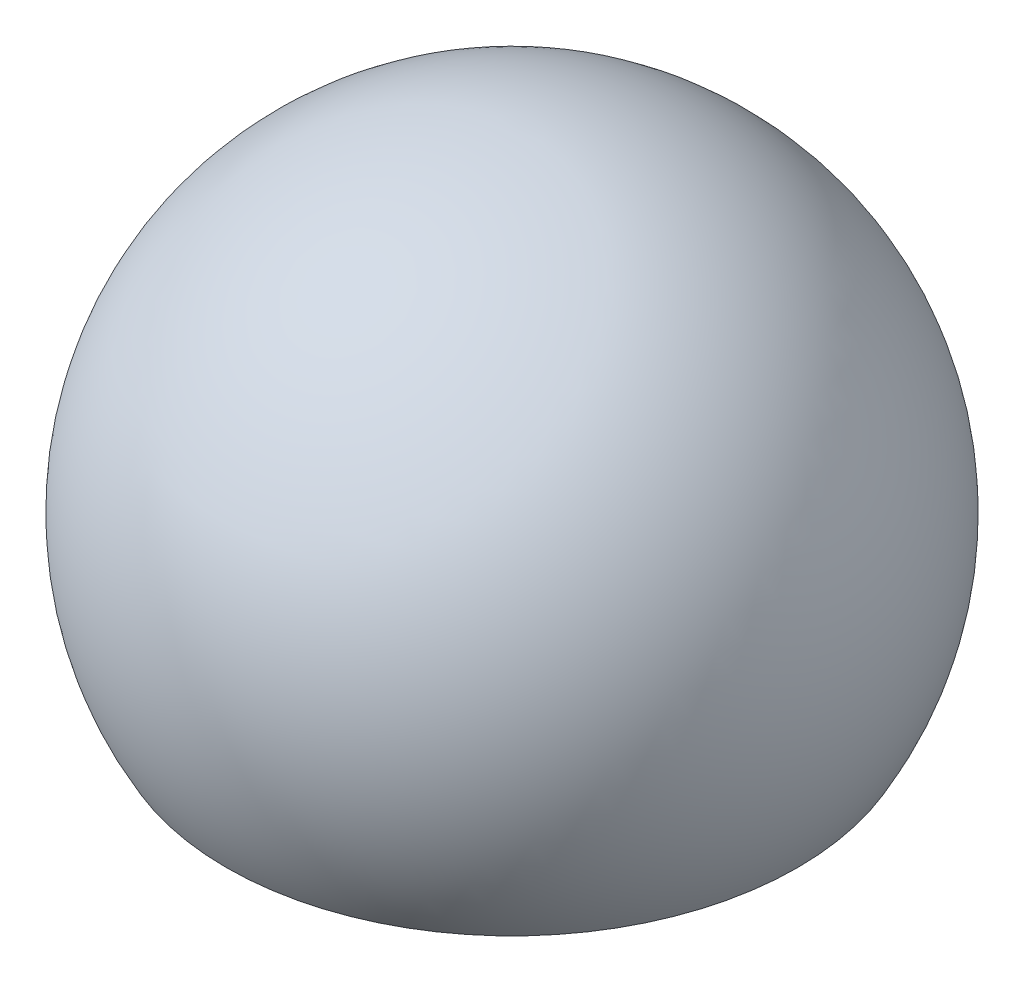
from build123d import *

# Parameters (mm, degrees)
TRUNCATED_BALL_DEPTH      = 13.7
TRUNCATED_BALL_DEPTH_BACK = 13.7
SKETCH8_W                 = 1.5875
SKETCH8_H                 = 11.1125


with BuildPart() as part:
    # Sketch1 → Complete_Ball (revolve)
    with BuildSketch(Plane.XY):
        with BuildLine():
            Line((0, 12.7), (0, -12.7))
            ThreePointArc((0, -12.7), (12.7, 0), (0, 12.7))
        make_face()
    revolve(axis=Axis((0, 13.6525, 0), (0, -1, 0)))

    # Sketch2 → Truncated_ball (cut, two sides)
    with BuildSketch(Plane.XY) as truncated_ball_sk:
        with BuildLine():
            Line((-10.998522628, -6.35), (10.998522628, -6.35))
            ThreePointArc((10.998522628, -6.35), (0, -12.7), (-10.998522628, -6.35))
        make_face()
    extrude(amount=TRUNCATED_BALL_DEPTH, mode=Mode.SUBTRACT)
    extrude(truncated_ball_sk.sketch, amount=-TRUNCATED_BALL_DEPTH_BACK, mode=Mode.SUBTRACT)

    # Sketch8 → Truncated_ball_w_blind_hole (revolve, cut)
    with BuildSketch(Plane.XY):
        with Locations((0.79375, -7.14375)):
            Rectangle(SKETCH8_W, SKETCH8_H)
    revolve(axis=Axis((0, 6.726898043, 0), (0, -1, 0)), mode=Mode.SUBTRACT)


solid = part.part
